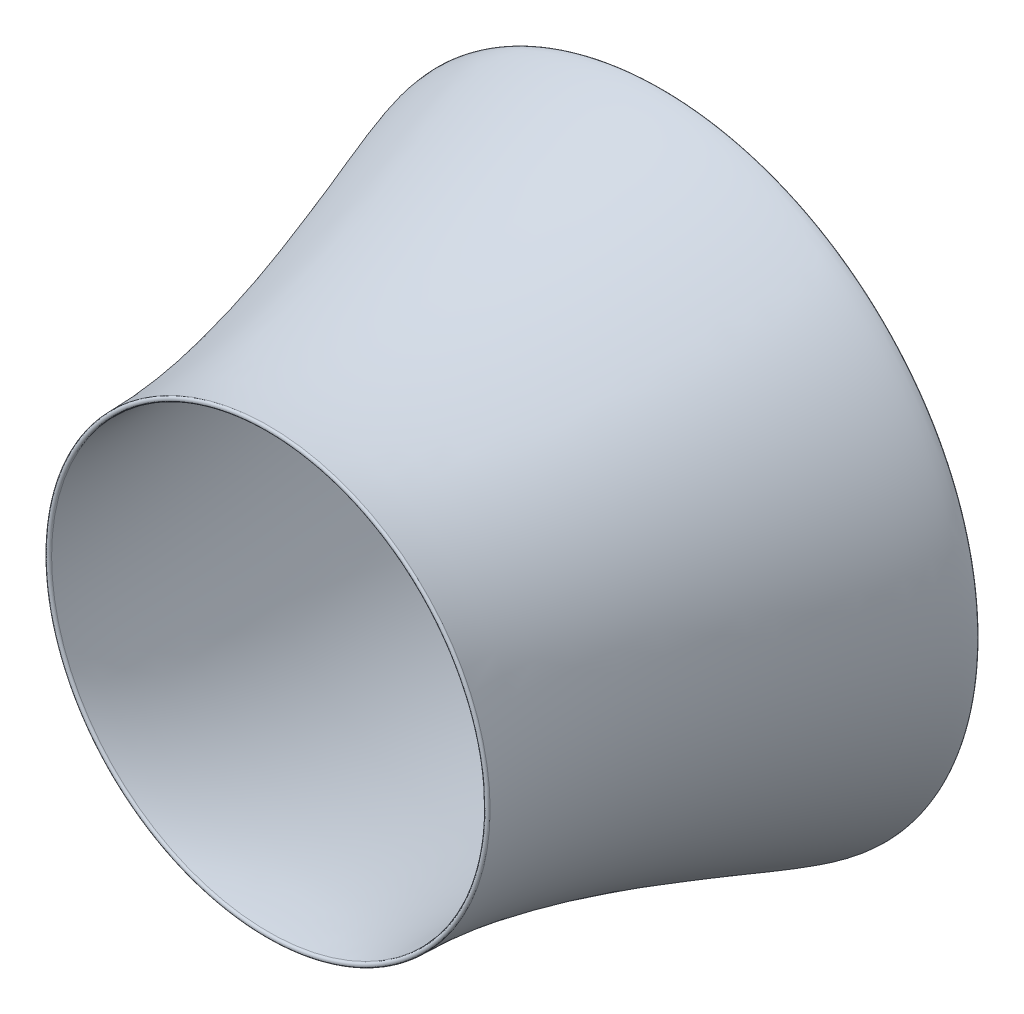
from build123d import *


with BuildPart() as part:
    # Sketch21 → Revolve2 (revolve)
    with BuildSketch(Plane(origin=(0, 0, 0), x_dir=(1, 0, 0), z_dir=(0, 1, 0))):
        with BuildLine():
            Line((-992.18018654, -1702.164815011), (-1013.883288312, -1702.164815011))
            add(Edge.make_bspline(
                [(-1447.715913467, 94.685748265), (-1447.715913467, -30.698204111), (-1013.883288312, -971.855694625), (-1013.883288312, -1702.164815011)],
                knots=[0, 0, 0, 0, 1, 1, 1, 1], degree=3))
            Line((-1447.715913467, 94.685748265), (-1232.826856147, 94.685748265))
            add(Edge.make_bspline(
                [(-1232.826856147, 94.685748265), (-1182.712200962, -46.381570775), (-1110.502599669, -571.312977983), (-953.763419276, -1319.304700659), (-992.18018654, -1702.164815011)],
                knots=[0, 0, 0, 0, 0.206506907, 1, 1, 1, 1], degree=3))
        make_face()
    revolve(axis=Axis((0, 0, 99.684784321), (0, 0, -1)))


with BuildPart() as body_2:
    # Sketch22 → Revolve3 (revolve)
    with BuildSketch(Plane(origin=(0, 0, 0), x_dir=(1, 0, 0), z_dir=(0, 1, 0))):
        with BuildLine():
            Line((-1447.715913467, 94.685748265), (-1232.826856147, 94.685748265))
            add(Edge.make_bspline(
                [(-1447.715913467, 94.685748265), (-1447.715913467, 111.619081598), (-1232.826856147, 111.619081598), (-1232.826856147, 94.685748265)],
                knots=[0, 0, 0, 0, 1, 1, 1, 1], degree=3))
        make_face()
    revolve(axis=Axis((0, 0, 99.684784321), (0, 0, -1)))


with BuildPart() as body_3:
    # Sketch23 → Revolve4 (revolve)
    with BuildSketch(Plane(origin=(0, 0, 0), x_dir=(1, 0, 0), z_dir=(0, 1, 0))):
        with BuildLine():
            Line((-1013.883288312, -1702.164815011), (-992.18018654, -1702.164815011))
            add(Edge.make_bspline(
                [(-1013.883288312, -1702.164815011), (-1013.883288312, -1714.864815011), (-992.18018654, -1714.864815011), (-992.18018654, -1702.164815011)],
                knots=[0, 0, 0, 0, 1, 1, 1, 1], degree=3))
        make_face()
    revolve(axis=Axis((0, 0, 1104.756830123), (0, 0, -1)))


solid = Compound([part.part, body_2.part, body_3.part])
